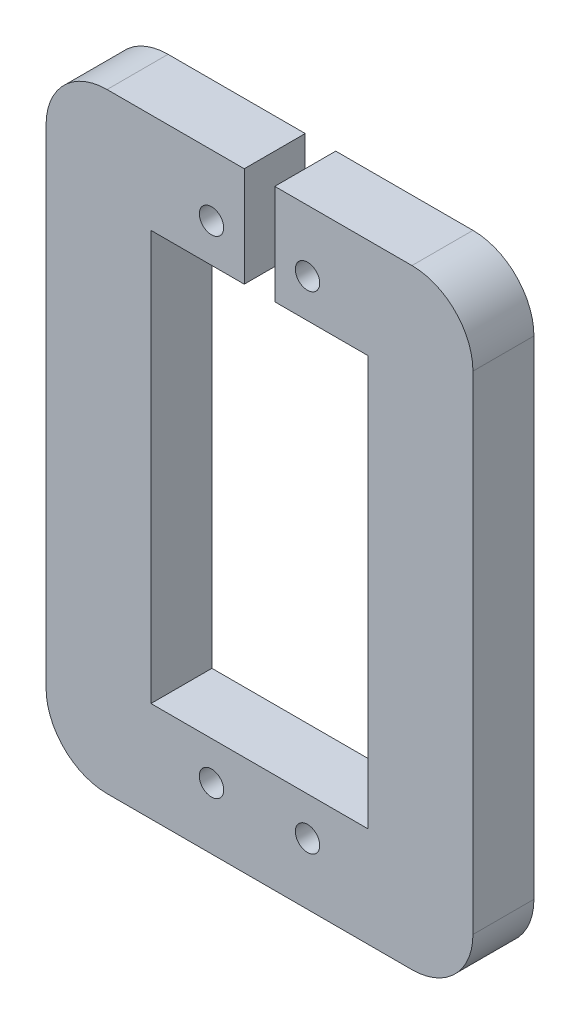
from build123d import *

# Parameters (mm, degrees)
SKETCH1_W           = 44.45
SKETCH1_H           = 63.5
SKETCH1_R           = 1.27
BOSS_EXTRUDE1_DEPTH = 6.35
SKETCH2_W           = 22.606
SKETCH2_H           = 42.672
CUT_EXTRUDE1_DEPTH  = 7.35
SKETCH3_W           = 3.175
SKETCH3_H           = 16.248427567
CUT_EXTRUDE2_DEPTH  = 7.35
FILLET1_R           = 6.35


with BuildPart() as part:
    # Sketch1 → Boss-Extrude1 (new body)
    with BuildSketch(Plane.XY):
        Rectangle(SKETCH1_W, SKETCH1_H)
        with Locations((-4.999806813, 25.351447061)):
            Circle(SKETCH1_R, mode=Mode.SUBTRACT)
        with Locations((4.999565199, 25.350804136)):
            Circle(SKETCH1_R, mode=Mode.SUBTRACT)
        with Locations((-5.000419542, -25.352292054)):
            Circle(SKETCH1_R, mode=Mode.SUBTRACT)
        with Locations((4.999806813, -25.351447061)):
            Circle(SKETCH1_R, mode=Mode.SUBTRACT)
    extrude(amount=BOSS_EXTRUDE1_DEPTH)

    # Sketch2 → Cut-Extrude1 (cut, through all)
    with BuildSketch(Plane.XY.offset(6.35)):
        Rectangle(SKETCH2_W, SKETCH2_H)
    extrude(amount=-CUT_EXTRUDE1_DEPTH, mode=Mode.SUBTRACT)

    # Sketch3 → Cut-Extrude2 (cut, through all)
    with BuildSketch(Plane.XY.offset(6.35)):
        with Locations((0, 27.215647874)):
            Rectangle(SKETCH3_W, SKETCH3_H)
    extrude(amount=-CUT_EXTRUDE2_DEPTH, mode=Mode.SUBTRACT)

    # Fillet1
    fillet1_edges = [part.edges().sort_by_distance(p)[0] for p in [
        (-22.225, 31.75, 3.175),
        (22.225, 31.75, 3.175),
        (22.225, -31.75, 3.175),
        (-22.225, -31.75, 3.175),
    ]]
    fillet(fillet1_edges, radius=FILLET1_R)


solid = part.part
